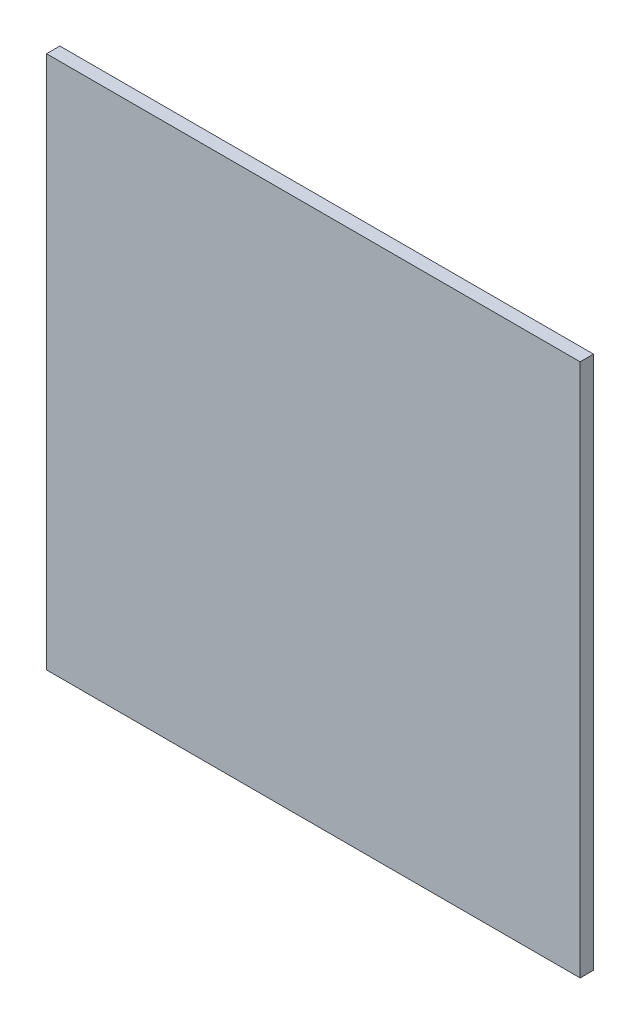
from build123d import *

# Parameters (mm, degrees)
SKETCH2_W           = 800
SKETCH2_H           = 800
BOSS_EXTRUDE1_DEPTH = 20


with BuildPart() as part:
    # Sketch2 → Boss-Extrude1 (new body)
    with BuildSketch(Plane.XY):
        Rectangle(SKETCH2_W, SKETCH2_H)
    extrude(amount=BOSS_EXTRUDE1_DEPTH)


solid = part.part
